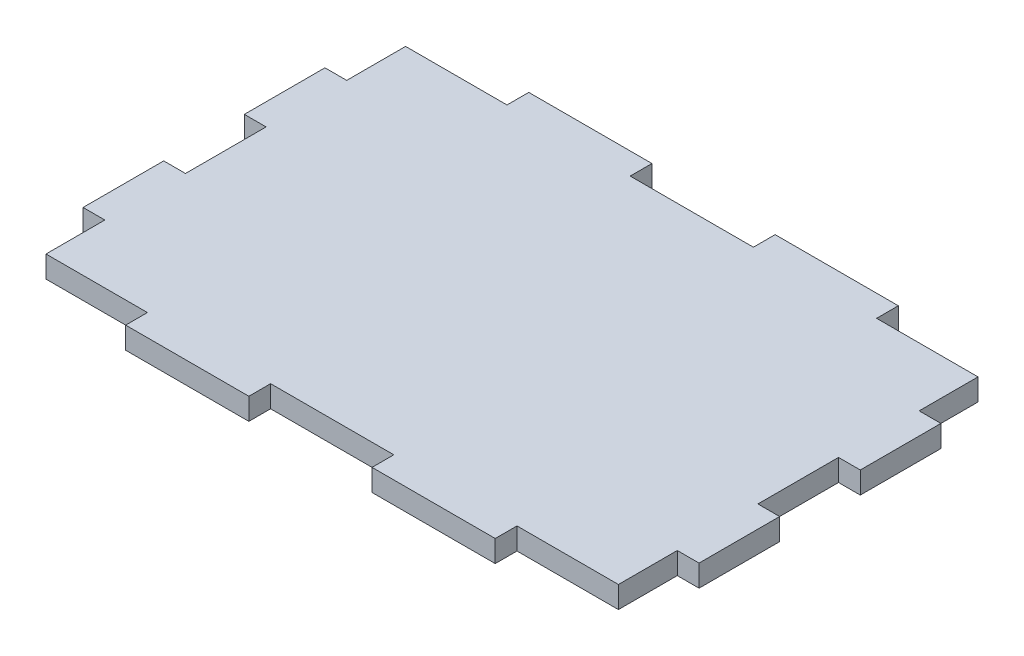
from build123d import *

# Parameters (mm, degrees)
BOSS_EXTRUDE1_DEPTH = 2.7


with BuildPart() as part:
    # Sketch1 → Boss-Extrude1 (new body)
    with BuildSketch(Plane(origin=(0, 0, 0), x_dir=(1, 0, 0), z_dir=(0, 1, 0))):
        Polygon((-22.92, 22.3), (-35.5, 22.3), (-35.5, 15), (-38.2, 15), (-38.2, 5), (-35.5, 5), (-35.5, -5), (-38.2, -5), (-38.2, -15), (-35.5, -15), (-35.5, -22.3), (-22.92, -22.3), (-22.92, -25), (-7.64, -25), (-7.64, -22.3), (7.64, -22.3), (7.64, -25), (22.92, -25), (22.92, -22.3), (35.5, -22.3), (35.5, -15), (38.2, -15), (38.2, -5), (35.5, -5), (35.5, 5), (38.2, 5), (38.2, 15), (35.5, 15), (35.5, 22.3), (22.92, 22.3), (22.92, 25), (7.64, 25), (7.64, 22.3), (-7.64, 22.3), (-7.64, 25), (-22.92, 25), align=None)
    extrude(amount=-BOSS_EXTRUDE1_DEPTH)


solid = part.part
